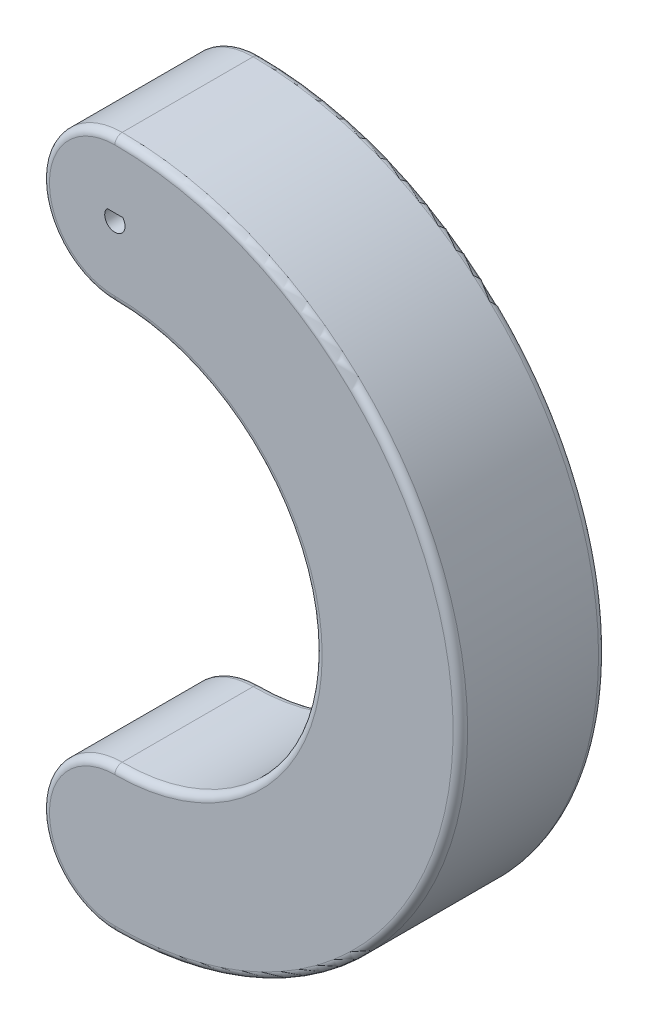
from build123d import *

# Parameters (mm, degrees)
BOSS_EXTRUDE1_DEPTH = 20
FILLET1_R           = 1


with BuildPart() as part:
    # Sketch1 → Boss-Extrude1 (new body)
    with BuildSketch(Plane.XY):
        with BuildLine():
            ThreePointArc((0, 10.635), (-10, 0.635), (0, -9.365))
            ThreePointArc((0, -9.365), (27.5, -36.865), (0, -64.365))
            ThreePointArc((0, -64.365), (-10, -74.365), (0, -84.365))
            ThreePointArc((0, -84.365), (47.5, -36.865), (0, 10.635))
        make_face()
        with BuildLine():
            ThreePointArc((1.072380529, 1.535), (0, -0.765), (-1.072380529, 1.535))
            Line((-1.072380529, 1.535), (1.072380529, 1.535))
        make_face(mode=Mode.SUBTRACT)
    extrude(amount=BOSS_EXTRUDE1_DEPTH)

    # Fillet1
    fillet1_edges = [part.edges().sort_by_distance(p)[0] for p in [
        (-10, 0.635, 20),
        (27.5, -36.865, 20),
        (-10, -74.365, 20),
        (47.5, -36.865, 20),
        (47.5, -36.865, 0),
        (-10, -74.365, 0),
        (27.5, -36.865, 0),
        (-10, 0.635, 0),
    ]]
    fillet(fillet1_edges, radius=FILLET1_R)


solid = part.part
